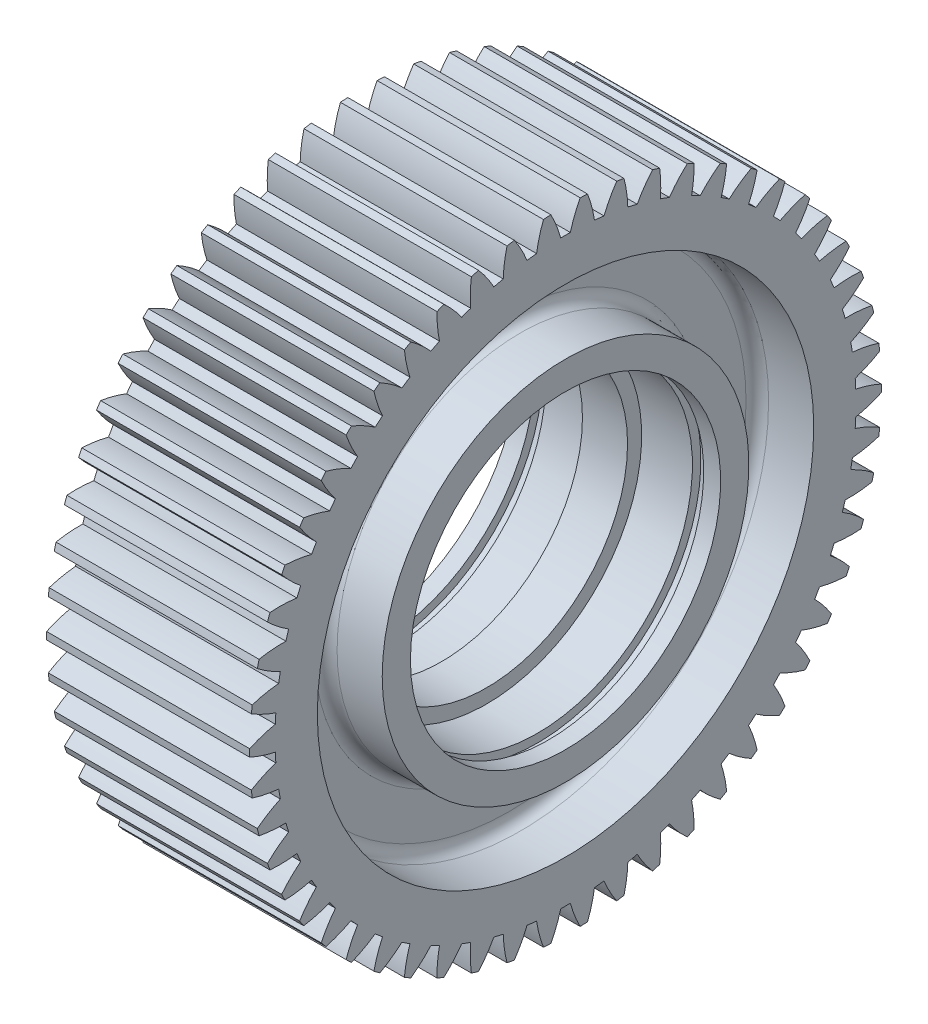
from build123d import *

# Parameters (mm, degrees)
BASPROSKE_W     = 36
BASPROSKE_H     = 56
TOOTHCUT_DEPTH  = 87.994252684
TEETHCUTS_COUNT = 54
BORSKE_R        = 25
BORE_DEPTH      = 50.0000508
SZKIC2_W        = 10
SZKIC2_H        = 11.5
ZAOKR_GLENIE1_R = 2


with BuildPart() as part:
    # BasProSke → Base-Revolve (revolve)
    with BuildSketch(Plane(origin=(0, 0, 0), x_dir=(1, 0, 0), z_dir=(0, 1, 0)), mode=Mode.PRIVATE) as base_revolve_sk:
        with Locations((18, 28)):
            Rectangle(BASPROSKE_W, BASPROSKE_H)
    revolve(base_revolve_sk.sketch.rotate(Axis((-10, 0, 0), (1, 0, 0)), 180), axis=Axis((-10, 0, 0), (1, 0, 0)))

    # TooCutSke → ToothCut (cut, through all)
    with BuildSketch(Plane(origin=(0, 0, 0), x_dir=(0, 0, -1), z_dir=(1, 0, 0))):
        with BuildLine():
            ThreePointArc((0.853930211, 51.491919795), (0, 51.499), (-0.853930211, 51.491919795))
            ThreePointArc((-0.853930211, 51.491919795), (-1.60941272, 53.777264131), (-2.614474643, 55.964363371))
            ThreePointArc((-2.614474643, 55.964363371), (0, 56.0254), (2.614474643, 55.964363371))
            ThreePointArc((2.614474643, 55.964363371), (1.60941272, 53.777264131), (0.853930211, 51.491919795))
        make_face()
    toothcut = extrude(amount=TOOTHCUT_DEPTH, mode=Mode.SUBTRACT)

    # TeethCuts: ToothCut ×54 about axis
    teethcuts_axis = Axis((0, 0, 0), (1, 0, 0))
    for i in range(1, TEETHCUTS_COUNT):
        add(toothcut.rotate(teethcuts_axis, i * 360 / TEETHCUTS_COUNT), mode=Mode.SUBTRACT)

    # BorSke → Bore (cut, symmetric)
    with BuildSketch(Plane(origin=(0, 0, 0), x_dir=(0, 0, -1), z_dir=(1, 0, 0))):
        with Locations(Location((0, 0, 0), (0, 0, 180))):
            Circle(BORSKE_R)
    extrude(amount=BORE_DEPTH, both=True, mode=Mode.SUBTRACT)

    # Szkic2 → Wyci_cie-obr_t1 (revolve, cut)
    with BuildSketch(Plane.XY, mode=Mode.PRIVATE) as wyci_cie_obr_t1_sk:
        Polygon((14, 27.5), (14, 0), (0, 0), (0, 27.5), (3, 27.5), (3, 29), (5, 29), (5, 27.5), align=None)
        with Locations((5, 38.25)):
            Rectangle(SZKIC2_W, SZKIC2_H)
    wyci_cie_obr_t1 = revolve(wyci_cie_obr_t1_sk.sketch.rotate(Axis((0, 0, 0), (1, 0, 0)), 90), axis=Axis((0, 0, 0), (1, 0, 0)), mode=Mode.SUBTRACT)

    # Lustro1: Wyci_cie-obr_t1 across plane
    add(wyci_cie_obr_t1.mirror(Plane.ZY.offset(-18)), mode=Mode.SUBTRACT)

    # Zaokr_glenie1
    zaokr_glenie1_edges = [part.edges().sort_by_distance(p)[0] for p in [
        (10, 0, -32.5),
        (10, 0, -44),
        (26, 0, -32.5),
        (26, 0, -44),
    ]]
    fillet(zaokr_glenie1_edges, radius=ZAOKR_GLENIE1_R)


solid = part.part
